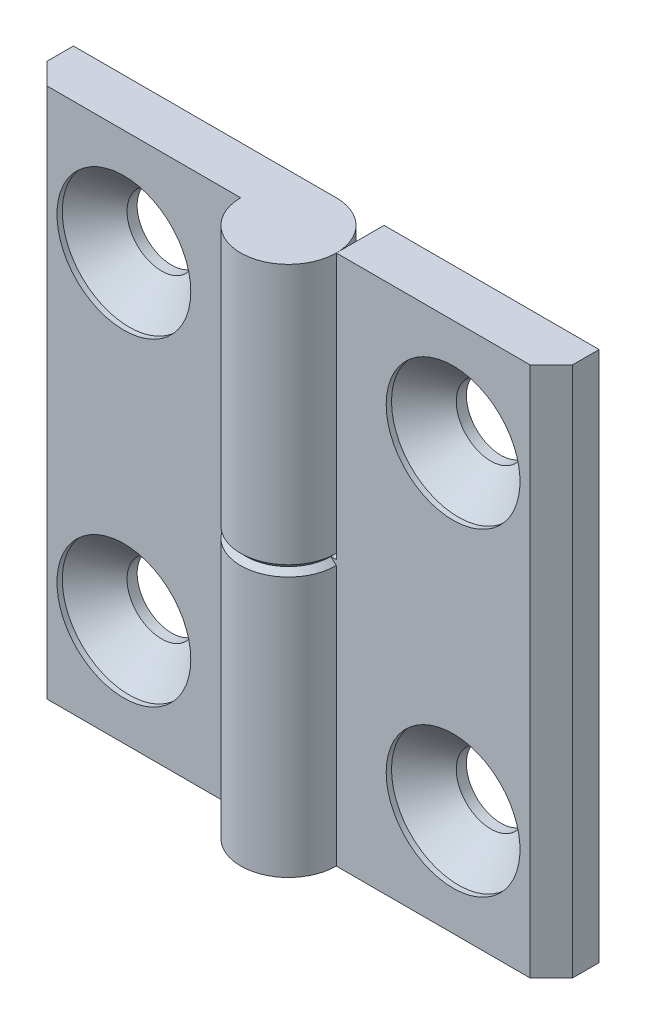
from build123d import *

# Parameters (mm, degrees)
EXTRUDE_1_DEPTH            = 25
SKETCH_3_W                 = 9
SKETCH_3_H                 = 25
CUT_EXTRUDE_1_DEPTH        = 5.5
CUT_EXTRUDE_1_DEPTH_BACK   = 5.5
HOLE_WIZARD_M61_AT_2_COUNT = 2
HOLE_WIZARD_M61_AT_2_PITCH = 30
CHAMFER_1_SIZE             = 0.5
PATTERN_CIRCULAR_1_COUNT   = 2


with BuildPart() as part:
    # Эскиз1 → Бобышка-Вытянуть1 (new body, symmetric)
    with BuildSketch(Plane(origin=(0, 0, 0), x_dir=(1, 0, 0), z_dir=(0, 1, 0))):
        with BuildLine():
            Line((0, 4.5), (-24.75, 4.5))
            Line((-24.75, 4.5), (-24.75, 2))
            Line((-24.75, 2), (-22.75, 0))
            Line((-22.75, 0), (-4.5, 0))
            ThreePointArc((-4.5, 0), (3.181980515, -3.181980515), (0, 4.5))
        make_face()
    extrude(amount=EXTRUDE_1_DEPTH, both=True)

    # Эскиз3 → Вырез-Вытянуть1 (cut, two sides)
    with BuildSketch(Plane.XY) as cut_extrude_1_sk:
        with Locations((0, -12.5)):
            Rectangle(SKETCH_3_W, SKETCH_3_H)
    extrude(amount=CUT_EXTRUDE_1_DEPTH, mode=Mode.SUBTRACT)
    extrude(cut_extrude_1_sk.sketch, amount=-CUT_EXTRUDE_1_DEPTH_BACK, mode=Mode.SUBTRACT)

    # Эскиз6 → Зенковка для винта с полупотайной головкой M61 (revolve, cut)
    with BuildSketch(Plane(origin=(-15.5, 15, 0), x_dir=(0, -1, 0), z_dir=(1, 0, 0))):
        Polygon((0, 0), (0, 4.5), (3.25, 4.5), (3.25, 3.55), (6.3, 0.5), (6.3, 0), align=None)
    hole_wizard_m61 = revolve(axis=Axis((-15.5, 15, 6.35), (0, 0, -1)), mode=Mode.SUBTRACT)

    # Зенковка для винта с полупотайной головкой M61 at 2: Зенковка для винта с полупотайной головкой M61 ×2
    with Locations(*[(0, -i * HOLE_WIZARD_M61_AT_2_PITCH, 0) for i in range(1, HOLE_WIZARD_M61_AT_2_COUNT)]):
        add(hole_wizard_m61, mode=Mode.SUBTRACT)

    # Фаска1
    chamfer_1_edges = [part.edges().sort_by_distance(p)[0] for p in [
        (3.181980515, 0, 3.181980515),
        (-2.25, 0, -4.5),
    ]]
    chamfer(chamfer_1_edges, length=CHAMFER_1_SIZE)


with BuildPart() as pattern_circular_1_1:
    # Круговой массив1: pattern copy
    add(part.part.rotate(Axis((0, 0, 0), (0, 0, 1)), 1 * 360 / PATTERN_CIRCULAR_1_COUNT))


solid = Compound([part.part, pattern_circular_1_1.part])
